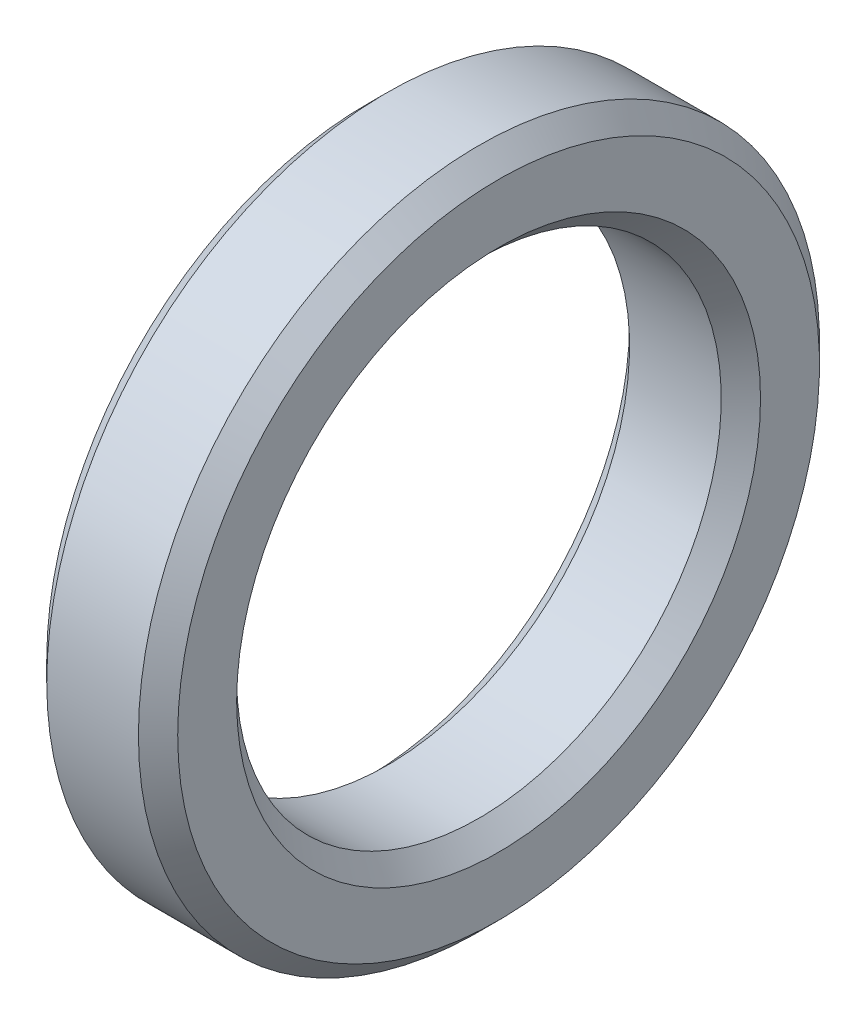
from build123d import *

# Parameters (mm, degrees)
HOLE_WIZARD_4_0_2_D     = 4
HOLE_WIZARD_4_0_2_DEPTH = 5
HOLE_WIZARD_4_0_2_TIP   = 1.201721238


with BuildPart() as part:
    # Эскиз1 → Повернуть1 (revolve)
    with BuildSketch(Plane.XY):
        Polygon((1.5, 18.5), (8.5, 18.5), (10, 20), (10, 24.5), (8.5, 26), (1.5, 26), (0, 24.5), (0, 20), align=None)
    revolve(axis=Axis((0, 0, 0), (1, 0, 0)))

    # Отверстия под штифты Ø4.0 мм2
    with Locations(Plane.ZY):
        with Locations((-22, 0), (0, 22), (22, 0), (0, -22)):
            Hole(HOLE_WIZARD_4_0_2_D / 2, depth=HOLE_WIZARD_4_0_2_DEPTH)
            with Locations((0, 0, -(HOLE_WIZARD_4_0_2_DEPTH + HOLE_WIZARD_4_0_2_TIP / 2))):  # 118° drill point
                Cone(0, HOLE_WIZARD_4_0_2_D / 2, HOLE_WIZARD_4_0_2_TIP, mode=Mode.SUBTRACT)


solid = part.part
